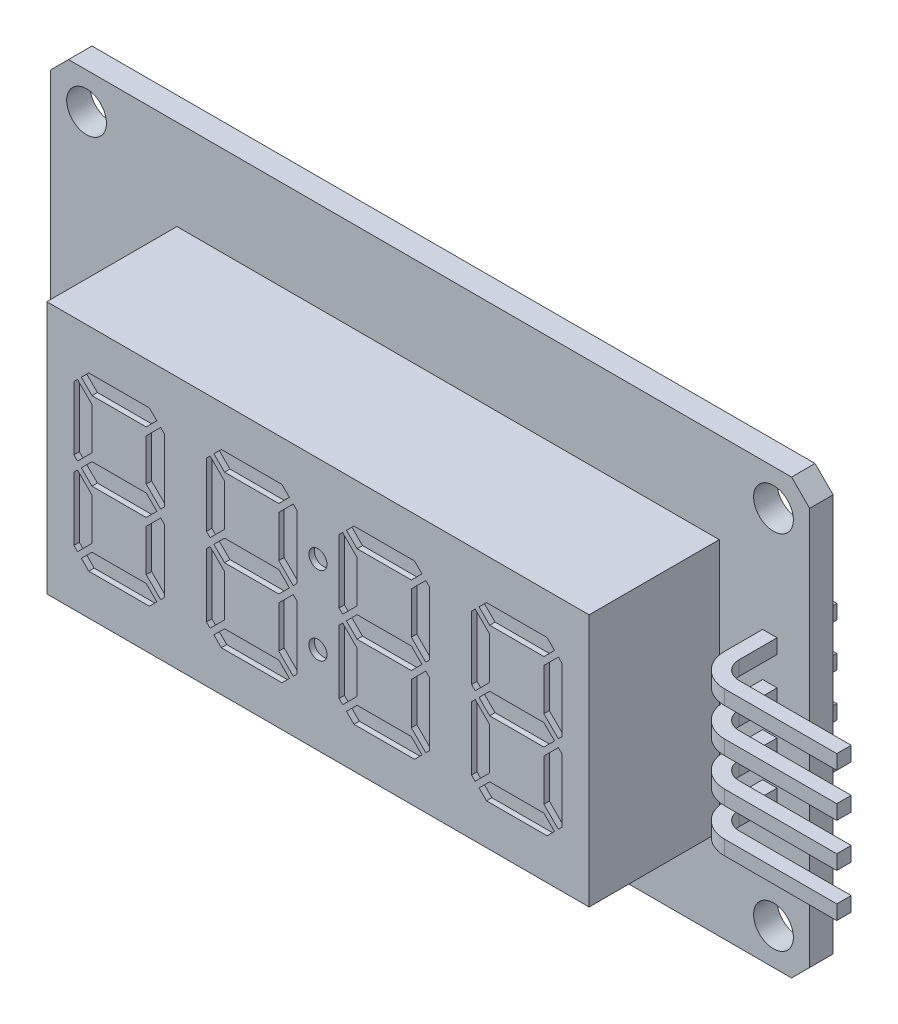
from build123d import *

# Parameters (mm, degrees)
SKETCH_1_R             = 1.1
EXTRUDE_1_DEPTH        = 1.3
SKETCH_2_W             = 30
SKETCH_2_H             = 14
EXTRUDE_2_DEPTH        = 7.2
SKETCH_3_W             = 8
SKETCH_3_H             = 13
EXTRUDE_3_DEPTH        = 2.5
EXTRUDE_4_DEPTH        = 0.4
PATTERN_LINEAR_1_COUNT = 4
PATTERN_LINEAR_1_PITCH = 2.4
CUT_EXTRUDE_1_DEPTH    = 0.3
SKETCH_7_R             = 0.5
CUT_EXTRUDE_2_DEPTH    = 0.3


with BuildPart() as part:
    # Эскиз1 → Бобышка-Вытянуть1 (new body)
    with BuildSketch(Plane.XY):
        Polygon((20, -12), (-20, -12), (-21, -11), (-21, 11), (-20, 12), (20, 12), (21, 11), (21, -11), align=None)
        with Locations((-19, 10)):
            Circle(SKETCH_1_R, mode=Mode.SUBTRACT)
        with Locations((19, 10)):
            Circle(SKETCH_1_R, mode=Mode.SUBTRACT)
        with Locations((19, -10)):
            Circle(SKETCH_1_R, mode=Mode.SUBTRACT)
        with Locations((-19, -10)):
            Circle(SKETCH_1_R, mode=Mode.SUBTRACT)
    extrude(amount=EXTRUDE_1_DEPTH)

    # Эскиз2 → Бобышка-Вытянуть2 (add)
    with BuildSketch(Plane.XY.offset(1.3)):
        with Locations((1, 0)):
            Rectangle(SKETCH_2_W, SKETCH_2_H)
    extrude(amount=EXTRUDE_2_DEPTH)

    # Эскиз3 → Бобышка-Вытянуть3 (add)
    with BuildSketch(Plane(origin=(0, 0, 0), x_dir=(-1, 0, 0), z_dir=(0, 0, -1))):
        with Locations((12.7, 0)):
            Rectangle(SKETCH_3_W, SKETCH_3_H)
    extrude(amount=EXTRUDE_3_DEPTH)

    # Эскиз4 → Бобышка-Вытянуть4 (add, symmetric)
    with BuildSketch(Plane(origin=(0, 3.5, 0), x_dir=(1, 0, 0), z_dir=(0, 1, 0))):
        with BuildLine():
            Line((18.4, 2), (18.4, -3.4))
            ThreePointArc((18.4, -3.4), (18.927207794, -4.672792206), (20.2, -5.2))
            Line((20.2, -5.2), (26.4, -5.2))
            Line((26.4, -5.2), (26.4, -4.4))
            Line((26.4, -4.4), (20.2, -4.4))
            ThreePointArc((20.2, -4.4), (19.492893219, -4.107106781), (19.2, -3.4))
            Line((19.2, -3.4), (19.2, 2))
            Line((19.2, 2), (18.4, 2))
        make_face()
    extrude_4 = extrude(amount=EXTRUDE_4_DEPTH, both=True)

    # Линейный массив1: Бобышка-Вытянуть4 ×4
    with Locations(*[(0, -i * PATTERN_LINEAR_1_PITCH, 0) for i in range(1, PATTERN_LINEAR_1_COUNT)]):
        add(extrude_4)

    # Эскиз5 → Вырез-Вытянуть1 (cut)
    with BuildSketch(Plane.XY.offset(8.5)):
        Polygon((-8.5, 3.75), (-11.5, 3.75), (-12.087867966, 4.337867966), (-11.675735931, 4.75), (-8.324264069, 4.75), (-7.912132034, 4.337867966), align=None)
        Polygon((-8.5, 0.587867966), (-11.5, 0.587867966), (-12.087867966, 0), (-11.5, -0.587867966), (-8.5, -0.587867966), (-7.912132034, 0), align=None)
        Polygon((-11.5, 1.012132034), (-11.5, 3.325735931), (-12.3, 4.125735931), (-12.5, 3.925735931), (-12.5, 0.412132034), (-12.3, 0.212132034), align=None)
        Polygon((-7.7, 0.212132034), (-7.5, 0.412132034), (-7.5, 3.925735931), (-7.7, 4.125735931), (-8.5, 3.325735931), (-8.5, 1.012132034), align=None)
        Polygon((-8.5, -3.75), (-7.912132034, -4.337867966), (-8.324264069, -4.75), (-11.675735931, -4.75), (-12.087867966, -4.337867966), (-11.5, -3.75), align=None)
        Polygon((-8.5, -1.012132034), (-8.5, -3.325735931), (-7.7, -4.125735931), (-7.5, -3.925735931), (-7.5, -0.412132034), (-7.7, -0.212132034), align=None)
        Polygon((-12.3, -0.212132034), (-12.5, -0.412132034), (-12.5, -3.925735931), (-12.3, -4.125735931), (-11.5, -3.325735931), (-11.5, -1.012132034), align=None)
        Polygon((-1.166666667, 3.75), (-4.166666667, 3.75), (-4.754534632, 4.337867966), (-4.342402598, 4.75), (-0.990930735, 4.75), (-0.578798701, 4.337867966), align=None)
        Polygon((-1.166666667, 0.587867966), (-4.166666667, 0.587867966), (-4.754534632, 0), (-4.166666667, -0.587867966), (-1.166666667, -0.587867966), (-0.578798701, 0), align=None)
        Polygon((-4.166666667, 1.012132034), (-4.166666667, 3.325735931), (-4.966666667, 4.125735931), (-5.166666667, 3.925735931), (-5.166666667, 0.412132034), (-4.966666667, 0.212132034), align=None)
        Polygon((-0.366666667, 0.212132034), (-0.166666667, 0.412132034), (-0.166666667, 3.925735931), (-0.366666667, 4.125735931), (-1.166666667, 3.325735931), (-1.166666667, 1.012132034), align=None)
        Polygon((-1.166666667, -3.75), (-0.578798701, -4.337867966), (-0.990930735, -4.75), (-4.342402598, -4.75), (-4.754534632, -4.337867966), (-4.166666667, -3.75), align=None)
        Polygon((-1.166666667, -1.012132034), (-1.166666667, -3.325735931), (-0.366666667, -4.125735931), (-0.166666667, -3.925735931), (-0.166666667, -0.412132034), (-0.366666667, -0.212132034), align=None)
        Polygon((-4.966666667, -0.212132034), (-5.166666667, -0.412132034), (-5.166666667, -3.925735931), (-4.966666667, -4.125735931), (-4.166666667, -3.325735931), (-4.166666667, -1.012132034), align=None)
        Polygon((6.166666667, 3.75), (3.166666667, 3.75), (2.578798701, 4.337867966), (2.990930735, 4.75), (6.342402598, 4.75), (6.754534632, 4.337867966), align=None)
        Polygon((6.166666667, 0.587867966), (3.166666667, 0.587867966), (2.578798701, 0), (3.166666667, -0.587867966), (6.166666667, -0.587867966), (6.754534632, 0), align=None)
        Polygon((3.166666667, 1.012132034), (3.166666667, 3.325735931), (2.366666667, 4.125735931), (2.166666667, 3.925735931), (2.166666667, 0.412132034), (2.366666667, 0.212132034), align=None)
        Polygon((6.966666667, 0.212132034), (7.166666667, 0.412132034), (7.166666667, 3.925735931), (6.966666667, 4.125735931), (6.166666667, 3.325735931), (6.166666667, 1.012132034), align=None)
        Polygon((6.166666667, -3.75), (6.754534632, -4.337867966), (6.342402598, -4.75), (2.990930735, -4.75), (2.578798701, -4.337867966), (3.166666667, -3.75), align=None)
        Polygon((6.166666667, -1.012132034), (6.166666667, -3.325735931), (6.966666667, -4.125735931), (7.166666667, -3.925735931), (7.166666667, -0.412132034), (6.966666667, -0.212132034), align=None)
        Polygon((2.366666667, -0.212132034), (2.166666667, -0.412132034), (2.166666667, -3.925735931), (2.366666667, -4.125735931), (3.166666667, -3.325735931), (3.166666667, -1.012132034), align=None)
        Polygon((13.5, 3.75), (10.5, 3.75), (9.912132034, 4.337867966), (10.324264069, 4.75), (13.675735931, 4.75), (14.087867966, 4.337867966), align=None)
        Polygon((13.5, 0.587867966), (10.5, 0.587867966), (9.912132034, 0), (10.5, -0.587867966), (13.5, -0.587867966), (14.087867966, 0), align=None)
        Polygon((10.5, 1.012132034), (10.5, 3.325735931), (9.7, 4.125735931), (9.5, 3.925735931), (9.5, 0.412132034), (9.7, 0.212132034), align=None)
        Polygon((14.3, 0.212132034), (14.5, 0.412132034), (14.5, 3.925735931), (14.3, 4.125735931), (13.5, 3.325735931), (13.5, 1.012132034), align=None)
        Polygon((13.5, -3.75), (14.087867966, -4.337867966), (13.675735931, -4.75), (10.324264069, -4.75), (9.912132034, -4.337867966), (10.5, -3.75), align=None)
        Polygon((13.5, -1.012132034), (13.5, -3.325735931), (14.3, -4.125735931), (14.5, -3.925735931), (14.5, -0.412132034), (14.3, -0.212132034), align=None)
        Polygon((9.7, -0.212132034), (9.5, -0.412132034), (9.5, -3.925735931), (9.7, -4.125735931), (10.5, -3.325735931), (10.5, -1.012132034), align=None)
    extrude(amount=-CUT_EXTRUDE_1_DEPTH, mode=Mode.SUBTRACT)

    # Эскиз7 → Вырез-Вытянуть2 (cut)
    with BuildSketch(Plane.XY.offset(8.5)):
        with Locations((1, 2.168933983)):
            Circle(SKETCH_7_R)
        with Locations((1, -2.168933983)):
            Circle(SKETCH_7_R)
    extrude(amount=-CUT_EXTRUDE_2_DEPTH, mode=Mode.SUBTRACT)


solid = part.part
